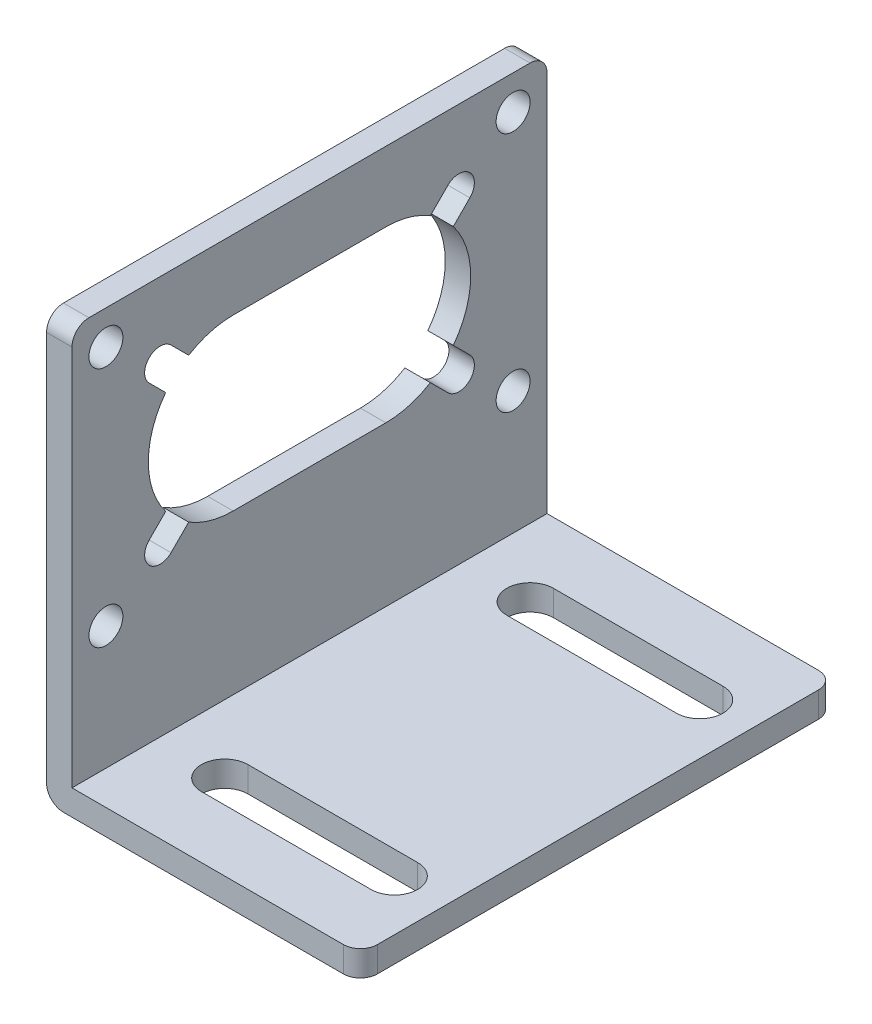
from build123d import *

# Parameters (mm, degrees)
EXTRUDE_1_DEPTH     = 56
CUT_EXTRUDE_1_DEPTH = 56
SKETCH_3_R          = 2
CUT_EXTRUDE_2_DEPTH = 4
FILLET_1_R          = 2


with BuildPart() as part:
    # 草图1 → 凸台-拉伸1 (new body)
    with BuildSketch(Plane.XY):
        Polygon((0, 0), (37, 0), (37, 3), (3, 3), (3, 50), (0, 50), align=None)
    extrude(amount=EXTRUDE_1_DEPTH)

    # 草图2 → 切除-拉伸1 (cut)
    with BuildSketch(Plane(origin=(0, 3, 0), x_dir=(1, 0, 0), z_dir=(0, 1, 0))):
        with BuildLine():
            Line((11, -12.75), (31, -12.75))
            ThreePointArc((31, -12.75), (33.75, -10), (31, -7.25))
            Line((31, -7.25), (11, -7.25))
            ThreePointArc((11, -7.25), (8.25, -10), (11, -12.75))
        make_face()
        with BuildLine():
            Line((11, -43.25), (31, -43.25))
            ThreePointArc((31, -43.25), (33.75, -46), (31, -48.75))
            Line((31, -48.75), (11, -48.75))
            ThreePointArc((11, -48.75), (8.25, -46), (11, -43.25))
        make_face()
    extrude(amount=-CUT_EXTRUDE_1_DEPTH, mode=Mode.SUBTRACT)

    # 草图3 → 切除-拉伸2 (cut, through all)
    with BuildSketch(Plane(origin=(3, 0, 0), x_dir=(0, 0, -1), z_dir=(1, 0, 0))):
        with Locations((-52, 46)):
            Circle(SKETCH_3_R)
        with Locations((-4, 46)):
            Circle(SKETCH_3_R)
        with Locations((-4, 17.533468943)):
            Circle(SKETCH_3_R)
        with Locations((-52, 17.533468943)):
            Circle(SKETCH_3_R)
        with BuildLine():
            Line((-37, 41.766734471), (-19, 41.766734471))
            ThreePointArc((-19, 41.766734471), (-16.276373136, 41.388681089), (-13.758681543, 40.283105813))
            Line((-13.758681543, 40.283105813), (-11.678664761, 42.363122594))
            ThreePointArc((-11.678664761, 42.363122594), (-9.099000833, 42.363122594), (-9.099000833, 39.783458666))
            Line((-9.099000833, 39.783458666), (-11.049840185, 37.832619314))
            ThreePointArc((-11.049840185, 37.832619314), (-9, 31.766734471), (-11.049840185, 25.700849629))
            Line((-11.049840185, 25.700849629), (-9.099000833, 23.750010277))
            ThreePointArc((-9.099000833, 23.750010277), (-9.099000833, 21.170346349), (-11.678664761, 21.170346349))
            Line((-11.678664761, 21.170346349), (-13.758681543, 23.25036313))
            ThreePointArc((-13.758681543, 23.25036313), (-16.276373136, 22.144787854), (-19, 21.766734471))
            Line((-19, 21.766734471), (-37, 21.766734471))
            ThreePointArc((-37, 21.766734471), (-39.723626864, 22.144787854), (-42.241318457, 23.25036313))
            Line((-42.241318457, 23.25036313), (-44.321335239, 21.170346349))
            ThreePointArc((-44.321335239, 21.170346349), (-46.900999167, 21.170346349), (-46.900999167, 23.750010277))
            Line((-46.900999167, 23.750010277), (-44.950159815, 25.700849629))
            ThreePointArc((-44.950159815, 25.700849629), (-47, 31.766734471), (-44.950159815, 37.832619314))
            Line((-44.950159815, 37.832619314), (-46.900999167, 39.783458666))
            ThreePointArc((-46.900999167, 39.783458666), (-46.900999167, 42.363122594), (-44.321335239, 42.363122594))
            Line((-44.321335239, 42.363122594), (-42.241318457, 40.283105813))
            ThreePointArc((-42.241318457, 40.283105813), (-39.723626864, 41.388681089), (-37, 41.766734471))
        make_face()
    extrude(amount=-CUT_EXTRUDE_2_DEPTH, mode=Mode.SUBTRACT)

    # 圆角1
    fillet_1_edges = [part.edges().sort_by_distance(p)[0] for p in [
        (37, 1.5, 56),
        (0, 0, 28),
        (1.5, 50, 56),
        (1.5, 50, 0),
        (37, 1.5, 0),
    ]]
    fillet(fillet_1_edges, radius=FILLET_1_R)


solid = part.part
